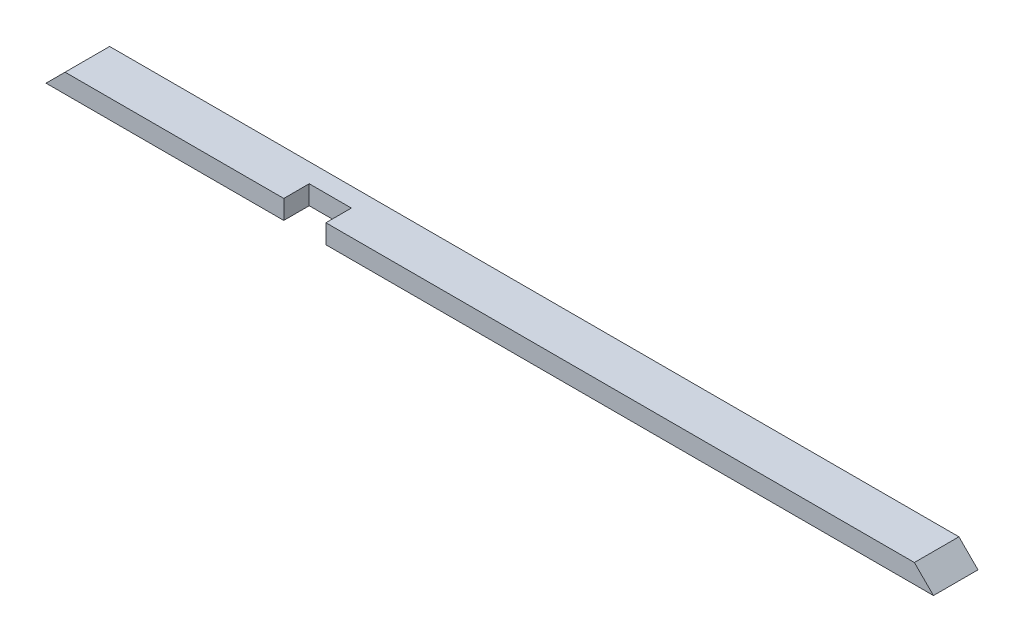
from build123d import *

# Parameters (mm, degrees)
SKETCH1_W           = 1771.65
SKETCH1_H           = 88.9
BOSS_EXTRUDE1_DEPTH = 38.1
CUT_EXTRUDE1_DEPTH  = 89.9
SKETCH3_W           = 84.1375
SKETCH3_H           = 50.8
CUT_EXTRUDE2_DEPTH  = 39.1


with BuildPart() as part:
    # Sketch1 → Boss-Extrude1 (new body)
    with BuildSketch(Plane(origin=(0, 0, 0), x_dir=(1, 0, 0), z_dir=(0, 1, 0))):
        with Locations((885.825, 44.45)):
            Rectangle(SKETCH1_W, SKETCH1_H)
    extrude(amount=BOSS_EXTRUDE1_DEPTH)

    # Sketch2 → Cut-Extrude1 (cut, through all)
    with BuildSketch(Plane.XY):
        Polygon((0, 0), (38.1, 38.1), (0, 38.1), align=None)
        Polygon((1771.65, 0), (1771.65, 38.1), (1733.55, 38.1), align=None)
    extrude(amount=-CUT_EXTRUDE1_DEPTH, mode=Mode.SUBTRACT)

    # Sketch3 → Cut-Extrude2 (cut, through all)
    with BuildSketch(Plane.XZ):
        with Locations((516.73125, -25.4)):
            Rectangle(SKETCH3_W, SKETCH3_H)
    extrude(amount=-CUT_EXTRUDE2_DEPTH, mode=Mode.SUBTRACT)


solid = part.part
